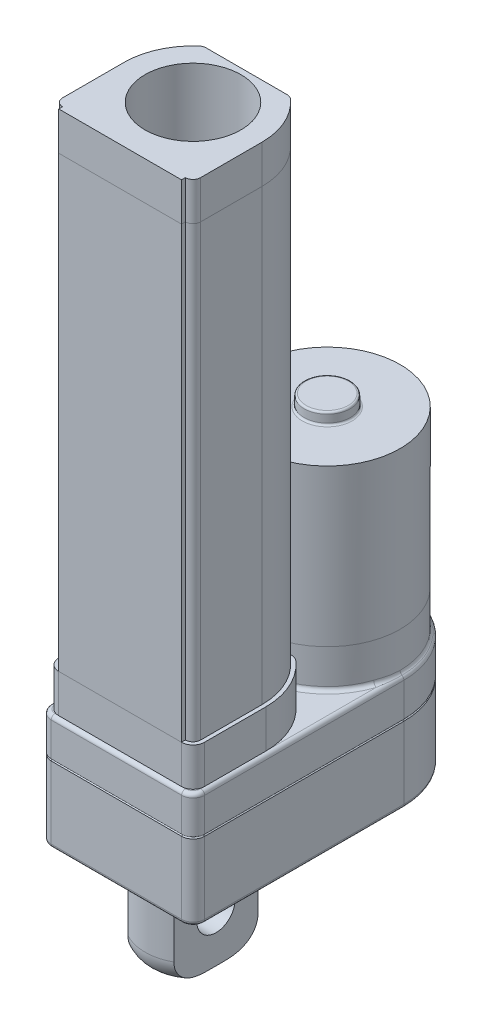
from build123d import *

# Parameters (mm, degrees)
BOSS_EXTRUDE1_DEPTH     = 30
FILLET1_R               = 1
SKETCH1_4_R             = 19
BOSS_EXTRUDE2_DEPTH     = 50.8
BOSS_EXTRUDE3_DEPTH     = 10
BOSS_EXTRUDE4_DEPTH     = 127
SKETCH3_R               = 6
BOSS_EXTRUDE5_DEPTH     = 3
FILLET2_R               = 1
FILLET3_R               = 0.5
SKETCH5_R               = 12.5
CUT_EXTRUDE4_DEPTH      = 500
BOSS_EXTRUDE7_DEPTH     = 25
SKETCH8_R               = 5
CUT_EXTRUDE5_DEPTH      = 21.0000001
CUT_EXTRUDE5_DEPTH_BACK = 21.0000001
CUT_SWEEP1_PROFILE_R    = 0.25
FILLET4_R               = 6.35


with BuildPart() as part:
    # Sketch1 → Boss-Extrude1 (new body)
    with BuildSketch(Plane(origin=(0, 0, 0), x_dir=(1, 0, 0), z_dir=(0, 1, 0))):
        with BuildLine():
            Line((-20, -16.958004219), (-20, 35))
            ThreePointArc((-20, 35), (0, 55), (20, 35))
            Line((20, 35), (20, -16.958004219))
            ThreePointArc((20, -16.958004219), (19.121320344, -19.079324562), (17, -19.958004219))
            Line((17, -19.958004219), (-17, -19.958004219))
            ThreePointArc((-17, -19.958004219), (-19.121320344, -19.079324562), (-20, -16.958004219))
        make_face()
    extrude(amount=-BOSS_EXTRUDE1_DEPTH)

    # Fillet1
    fillet1_edges = [part.edges().sort_by_distance(p)[0] for p in [
        (0, -30, 19.958004219),
        (-19.121320344, 0, 19.079324562),
        (19.121320344, -30, 19.079324562),
        (20, -30, -9.020997891),
        (0, -30, -55),
        (-20, -30, -9.020997891),
        (-19.121320344, -30, 19.079324562),
        (-20, 0, -9.020997891),
        (0, 0, -55),
        (20, 0, -9.020997891),
        (19.121320344, 0, 19.079324562),
        (0, 0, 19.958004219),
    ]]
    fillet(fillet1_edges, radius=FILLET1_R)

    # Sketch1_4 → Boss-Extrude2 (add)
    with BuildSketch(Plane(origin=(0, 0, 0), x_dir=(1, 0, 0), z_dir=(0, 1, 0))):
        with Locations((0, 35)):
            Circle(SKETCH1_4_R)
    extrude(amount=BOSS_EXTRUDE2_DEPTH)

    # Sketch3 → Boss-Extrude5 (add)
    with BuildSketch(Plane(origin=(0, 50.8, 0), x_dir=(1, 0, 0), z_dir=(0, 1, 0))):
        with Locations((0, 35)):
            Circle(SKETCH3_R)
    extrude(amount=BOSS_EXTRUDE5_DEPTH)

    # Fillet2
    fillet2_edges = [part.edges().sort_by_distance(p)[0] for p in [
        (0, 0, -54),
        (0, 0, -16),
    ]]
    fillet(fillet2_edges, radius=FILLET2_R)

    # Fillet3
    fillet3_edges = [part.edges().sort_by_distance(p)[0] for p in [
        (-6, 50.8, -35),
        (-6, 53.8, -35),
    ]]
    fillet(fillet3_edges, radius=FILLET3_R)

    # Sketch6 → Boss-Extrude7 (add)
    with BuildSketch(Plane.XZ.offset(30)):
        with BuildLine():
            Line((-6, 10.9658561), (-6, -10.9658561))
            ThreePointArc((-6, -10.9658561), (0, -12.5), (6, -10.9658561))
            Line((6, -10.9658561), (6, 10.9658561))
            ThreePointArc((6, 10.9658561), (0, 12.5), (-6, 10.9658561))
        make_face()
    extrude(amount=BOSS_EXTRUDE7_DEPTH)

    # Sketch8 → Cut-Extrude5 (cut, two sides)
    with BuildSketch(Plane(origin=(0, 0, 0), x_dir=(0, 0, -1), z_dir=(1, 0, 0))) as cut_extrude5_sk:
        with Locations((0, -42.5)):
            Circle(SKETCH8_R)
    extrude(amount=CUT_EXTRUDE5_DEPTH, mode=Mode.SUBTRACT)
    extrude(cut_extrude5_sk.sketch, amount=-CUT_EXTRUDE5_DEPTH_BACK, mode=Mode.SUBTRACT)

    # Cut-Sweep1: sweep along a path in Sketch9
    with BuildLine(Plane(origin=(0, -10, 0), x_dir=(-1, 0, 0), z_dir=(0, -1, 0))) as cut_sweep1_path:
        Line((-20, -16.958004219), (-20, 35))
        ThreePointArc((-20, 35), (0, 55), (20, 35))
        Line((20, 35), (20, -16.958004219))
        ThreePointArc((20, -16.958004219), (19.121320344, -19.079324562), (17, -19.958004219))
        Line((17, -19.958004219), (-17, -19.958004219))
        ThreePointArc((-17, -19.958004219), (-19.121320344, -19.079324562), (-20, -16.958004219))
    # Cut-Sweep1 profile (on start of the path) → Cut-Sweep1 (sweep, cut)
    with BuildSketch(Plane(origin=(20, -10, 16.958004219), x_dir=(-1, 0, 0), z_dir=(0, 0, -1))):
        Circle(CUT_SWEEP1_PROFILE_R)
    sweep(path=cut_sweep1_path.line, mode=Mode.SUBTRACT)

    # Fillet4
    fillet4_edges = [part.edges().sort_by_distance(p)[0] for p in [
        (0, -55, -12.5),
        (0, -55, 12.5),
    ]]
    fillet(fillet4_edges, radius=FILLET4_R)


with BuildPart() as body_2:
    # Sketch1_5 → Boss-Extrude3 (new body)
    with BuildSketch(Plane(origin=(0, 0, 0), x_dir=(1, 0, 0), z_dir=(0, 1, 0))):
        with BuildLine():
            Line((-10.583005244, 15), (10.583005244, 15))
            ThreePointArc((10.583005244, 15), (11.643665416, 14.80624304), (12.567318728, 14.25))
            ThreePointArc((12.567318728, 14.25), (17.317318728, 7.817318728), (19, 0))
            Line((19, 0), (19, -16))
            ThreePointArc((19, -16), (18.121320344, -18.121320344), (16, -19))
            Line((16, -19), (-16, -19))
            ThreePointArc((-16, -19), (-18.121320344, -18.121320344), (-19, -16))
            Line((-19, -16), (-19, 0))
            ThreePointArc((-19, 0), (-17.317318728, 7.817318728), (-12.567318728, 14.25))
            ThreePointArc((-12.567318728, 14.25), (-11.643665416, 14.80624304), (-10.583005244, 15))
        make_face()
    extrude(amount=BOSS_EXTRUDE3_DEPTH)


with BuildPart() as body_3:
    # Sketch2 → Boss-Extrude4 (new body)
    with BuildSketch(Plane(origin=(0, 10, 0), x_dir=(1, 0, 0), z_dir=(0, 1, 0))):
        with BuildLine():
            Line((-18, 0), (-18, -16))
            ThreePointArc((-18, -16), (-17.414213562, -17.414213562), (-16, -18))
            Line((-16, -18), (-16, -19))
            Line((-16, -19), (16, -19))
            Line((16, -19), (16, -18))
            ThreePointArc((16, -18), (17.414213562, -17.414213562), (18, -16))
            Line((18, -16), (18, 0))
            ThreePointArc((18, 0), (16.4058809, 7.4058809), (11.9058809, 13.5))
            ThreePointArc((11.9058809, 13.5), (11.290112025, 13.870828693), (10.583005244, 14))
            Line((10.583005244, 14), (-10.583005244, 14))
            ThreePointArc((-10.583005244, 14), (-11.290112025, 13.870828693), (-11.9058809, 13.5))
            ThreePointArc((-11.9058809, 13.5), (-16.4058809, 7.4058809), (-18, 0))
        make_face()
    extrude(amount=BOSS_EXTRUDE4_DEPTH)

    # Sketch5 → Cut-Extrude4 (cut)
    with BuildSketch(Plane(origin=(0, 137, 0), x_dir=(1, 0, 0), z_dir=(0, 1, 0))):
        Circle(SKETCH5_R)
    extrude(amount=-CUT_EXTRUDE4_DEPTH, mode=Mode.SUBTRACT)


solid = Compound([part.part, body_2.part, body_3.part])
